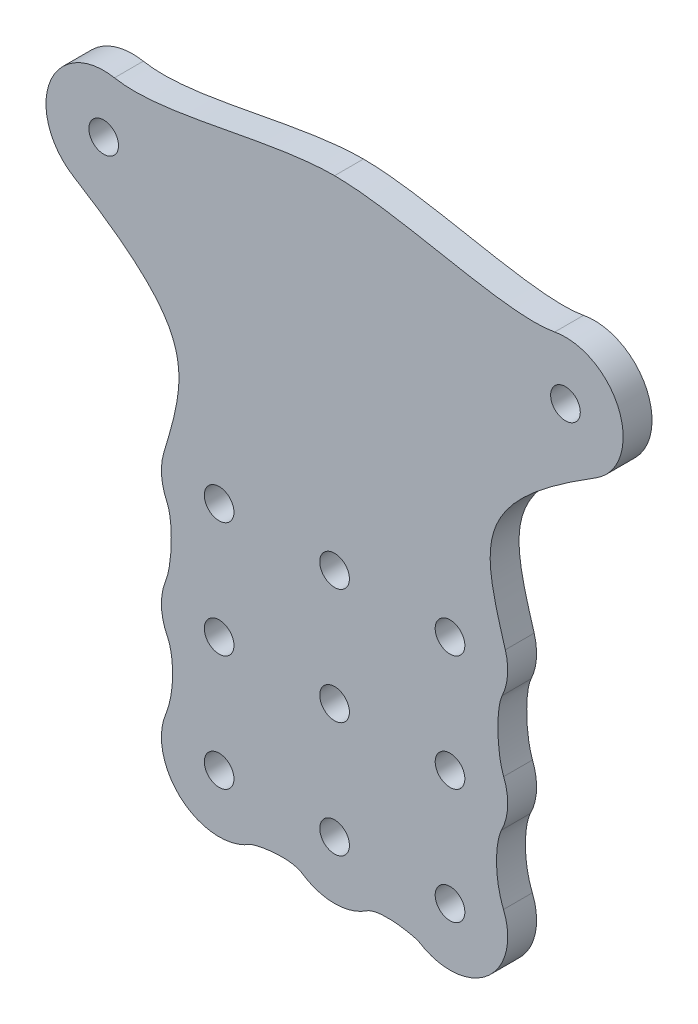
from build123d import *

# Parameters (mm, degrees)
SKETCH1_R           = 3.2639
BOSS_EXTRUDE1_DEPTH = 6.35


with BuildPart() as part:
    # Sketch1 → Boss-Extrude1 (new body)
    with BuildSketch(Plane.XY):
        with BuildLine():
            ThreePointArc((-57.473802429, -10.805108104), (-44.614019514, -11.091602473), (-38.1, 0))
            ThreePointArc((-38.1, 0), (-41.01784601, 8.099349561), (-48.430624144, 12.477021201))
            ThreePointArc((-48.430624144, 12.477021201), (-62.638344828, 4.598216146), (-57.473802429, -10.805108104))
        make_face()
        with Locations((-50.8, 0)):
            Circle(SKETCH1_R, mode=Mode.SUBTRACT)
        with BuildLine():
            ThreePointArc((-48.430624144, 12.477021201), (-41.01784601, 8.099349561), (-38.1, 0))
            ThreePointArc((-38.1, 0), (-44.614019514, -11.091602473), (-57.473802429, -10.805108104))
            add(Edge.make_bspline(
                [(-57.473802429, -10.805108104), (-30.324225084, -27.574113421), (-32.043298334, -35.040779529), (-37.567450056, -53.510884843)],
                knots=[0, 0, 0, 0, 1, 1, 1, 1], degree=3))
            ThreePointArc((-37.567450056, -53.510884843), (-23.561062225, -44.583842757), (-12.7, -57.15))
            ThreePointArc((-12.7, -57.15), (-16.419743871, -66.130256114), (-25.399999979, -69.85))
            ThreePointArc((-25.399999979, -69.85), (-16.419743871, -73.569743886), (-12.7, -82.55))
            ThreePointArc((-12.7, -82.55), (-16.419743827, -91.530256069), (-25.399999853, -95.25))
            ThreePointArc((-25.399999853, -95.25), (-16.419743827, -98.969743931), (-12.7, -107.95))
            ThreePointArc((-12.7, -107.95), (0, -95.25), (12.7, -107.95))
            ThreePointArc((12.7, -107.95), (16.419743879, -98.969743879), (25.4, -95.25))
            ThreePointArc((25.4, -95.25), (12.7, -82.55), (25.4, -69.85))
            ThreePointArc((25.4, -69.85), (15.214059629, -49.564710371), (37.567450056, -53.510884843))
            add(Edge.make_bspline(
                [(57.473802429, -10.805108104), (30.324225084, -27.574113421), (32.043298334, -35.040779529), (37.567450056, -53.510884843)],
                knots=[0, 0, 0, 0, 1, 1, 1, 1], degree=3))
            ThreePointArc((57.473802429, -10.805108104), (38.961655172, -4.598216146), (48.430624144, 12.477021201))
            add(Edge.make_bspline(
                [(48.430624144, 12.477021201), (37.357152211, 10.374178173), (14.965004226, 18.047449429), (0, 18.047449429)],
                knots=[0, 0, 0, 0, 1, 1, 1, 1], degree=3))
            add(Edge.make_bspline(
                [(-48.430624144, 12.477021201), (-37.357152211, 10.374178173), (-14.965004226, 18.047449429), (0, 18.047449429)],
                knots=[0, 0, 0, 0, 1, 1, 1, 1], degree=3))
        make_face()
        with Locations((0, -82.55)):
            Circle(SKETCH1_R, mode=Mode.SUBTRACT)
        with Locations((0, -57.15)):
            Circle(SKETCH1_R, mode=Mode.SUBTRACT)
        with BuildLine():
            ThreePointArc((-12.7, -57.15), (-23.561062225, -44.583842757), (-37.567450056, -53.510884843))
            ThreePointArc((-37.567450056, -53.510884843), (-38.064116275, -58.104022521), (-36.884933285, -62.570913894))
            ThreePointArc((-36.884933285, -62.570913894), (-32.198690804, -67.876966176), (-25.399999979, -69.85))
            ThreePointArc((-25.399999979, -69.85), (-16.419743871, -66.130256114), (-12.7, -57.15))
        make_face()
        with Locations((-25.4, -57.15)):
            Circle(SKETCH1_R, mode=Mode.SUBTRACT)
        with BuildLine():
            ThreePointArc((63.5, 0), (58.899349561, 9.78215399), (48.430624144, 12.477021201))
            ThreePointArc((48.430624144, 12.477021201), (38.961655172, -4.598216146), (57.473802429, -10.805108104))
            ThreePointArc((57.473802429, -10.805108104), (61.891602473, -6.185980486), (63.5, 0))
        make_face()
        with Locations((50.8, 0)):
            Circle(SKETCH1_R, mode=Mode.SUBTRACT)
        with BuildLine():
            ThreePointArc((-25.399999979, -69.85), (-32.198690804, -67.876966176), (-36.884933285, -62.570913894))
            add(Edge.make_bspline(
                [(-36.884933285, -62.570913894), (-35.474995699, -65.558055809), (-35.667347264, -73.999879631), (-37.201234877, -77.857361577)],
                knots=[0, 0, 0, 0, 1, 1, 1, 1], degree=3))
            ThreePointArc((-37.201234877, -77.857361577), (-32.530690422, -72.040801453), (-25.399999979, -69.85))
        make_face()
        with BuildLine():
            ThreePointArc((-12.7, -82.55), (-16.419743871, -73.569743886), (-25.399999979, -69.85))
            ThreePointArc((-25.399999979, -69.85), (-32.530690422, -72.040801453), (-37.201234877, -77.857361577))
            ThreePointArc((-37.201234877, -77.857361577), (-38.087106538, -83.122125598), (-36.730964647, -88.285785925))
            ThreePointArc((-36.730964647, -88.285785925), (-32.050019439, -93.369761617), (-25.399999853, -95.25))
            ThreePointArc((-25.399999853, -95.25), (-16.419743827, -91.530256069), (-12.7, -82.55))
        make_face()
        with Locations((-25.4, -82.55)):
            Circle(SKETCH1_R, mode=Mode.SUBTRACT)
        with BuildLine():
            ThreePointArc((38.1, -57.15), (37.966157243, -55.311062225), (37.567450056, -53.510884843))
            ThreePointArc((37.567450056, -53.510884843), (15.214059629, -49.564710371), (25.4, -69.85))
            ThreePointArc((25.4, -69.85), (32.198690813, -67.876966171), (36.884933285, -62.570913894))
            ThreePointArc((36.884933285, -62.570913894), (37.792510898, -59.927710144), (38.1, -57.15))
        make_face()
        with Locations((25.4, -57.15)):
            Circle(SKETCH1_R, mode=Mode.SUBTRACT)
        with BuildLine():
            ThreePointArc((-25.399999853, -95.25), (-32.050019439, -93.369761617), (-36.730964647, -88.285785925))
            add(Edge.make_bspline(
                [(-36.730964647, -88.285785925), (-35.529540216, -90.659183036), (-34.868854283, -97.491227569), (-37.173139537, -103.187313212)],
                knots=[0, 0, 0, 0, 1, 1, 1, 1], degree=3))
            ThreePointArc((-37.173139537, -103.187313212), (-32.499432233, -97.419659931), (-25.399999853, -95.25))
        make_face()
        with BuildLine():
            ThreePointArc((36.884933285, -62.570913894), (32.198690813, -67.876966171), (25.4, -69.85))
            ThreePointArc((25.4, -69.85), (32.53069043, -72.040801459), (37.201234877, -77.857361577))
            add(Edge.make_bspline(
                [(36.884933285, -62.570913894), (35.474995699, -65.558055809), (35.667347264, -73.999879631), (37.201234877, -77.857361577)],
                knots=[0, 0, 0, 0, 1, 1, 1, 1], degree=3))
        make_face()
        with BuildLine():
            ThreePointArc((37.201234877, -77.857361577), (32.53069043, -72.040801459), (25.4, -69.85))
            ThreePointArc((25.4, -69.85), (12.7, -82.55), (25.4, -95.25))
            ThreePointArc((25.4, -95.25), (32.050019502, -93.369761579), (36.730964647, -88.285785925))
            ThreePointArc((36.730964647, -88.285785925), (37.753000668, -85.498452898), (38.1, -82.55))
            ThreePointArc((38.1, -82.55), (37.873285111, -80.161034004), (37.201234877, -77.857361577))
        make_face()
        with Locations((25.4, -82.55)):
            Circle(SKETCH1_R, mode=Mode.SUBTRACT)
        with BuildLine():
            ThreePointArc((-12.7, -107.95), (-16.419743827, -98.969743931), (-25.399999853, -95.25))
            ThreePointArc((-25.399999853, -95.25), (-32.499432233, -97.419659931), (-37.173139537, -103.187313212))
            ThreePointArc((-37.173139537, -103.187313212), (-33.490567042, -117.73941903), (-18.505322211, -118.615524749))
            ThreePointArc((-18.505322211, -118.615524749), (-14.245350567, -114.021556311), (-12.7, -107.95))
        make_face()
        with Locations((-25.4, -107.95)):
            Circle(SKETCH1_R, mode=Mode.SUBTRACT)
        with BuildLine():
            ThreePointArc((36.730964647, -88.285785925), (32.050019502, -93.369761579), (25.4, -95.25))
            ThreePointArc((25.4, -95.25), (32.499432294, -97.419659972), (37.173139537, -103.187313212))
            add(Edge.make_bspline(
                [(36.730964647, -88.285785925), (35.529540216, -90.659183036), (34.868854283, -97.491227569), (37.173139537, -103.187313212)],
                knots=[0, 0, 0, 0, 1, 1, 1, 1], degree=3))
        make_face()
        with BuildLine():
            ThreePointArc((37.173139537, -103.187313212), (32.499432294, -97.419659972), (25.4, -95.25))
            ThreePointArc((25.4, -95.25), (16.419743879, -98.969743879), (12.7, -107.95))
            ThreePointArc((12.7, -107.95), (14.245350567, -114.021556311), (18.505322211, -118.615524749))
            ThreePointArc((18.505322211, -118.615524749), (31.471556311, -119.104649433), (38.1, -107.95))
            ThreePointArc((38.1, -107.95), (37.86613156, -105.523981876), (37.173139537, -103.187313212))
        make_face()
        with Locations((25.4, -107.95)):
            Circle(SKETCH1_R, mode=Mode.SUBTRACT)
        with BuildLine():
            ThreePointArc((12.7, -107.95), (0, -95.25), (-12.7, -107.95))
            ThreePointArc((-12.7, -107.95), (-11.196292989, -113.94441601), (-7.041256172, -118.519328811))
            ThreePointArc((-7.041256172, -118.519328811), (0, -120.65), (7.041256172, -118.519328811))
            ThreePointArc((7.041256172, -118.519328811), (11.196292989, -113.94441601), (12.7, -107.95))
        make_face()
        with Locations((0, -107.95)):
            Circle(SKETCH1_R, mode=Mode.SUBTRACT)
        with BuildLine():
            ThreePointArc((-7.041256172, -118.519328811), (-11.196292989, -113.94441601), (-12.7, -107.95))
            ThreePointArc((-12.7, -107.95), (-14.245350567, -114.021556311), (-18.505322211, -118.615524749))
            add(Edge.make_bspline(
                [(-18.505322211, -118.615524749), (-17.94171439, -118.251183152), (-10.184581564, -116.42525456), (-7.041256172, -118.519328811)],
                knots=[0, 0, 0, 0, 1, 1, 1, 1], degree=3))
        make_face()
        with BuildLine():
            ThreePointArc((18.505322211, -118.615524749), (14.245350567, -114.021556311), (12.7, -107.95))
            ThreePointArc((12.7, -107.95), (11.196292989, -113.94441601), (7.041256172, -118.519328811))
            add(Edge.make_bspline(
                [(18.505322211, -118.615524749), (17.94171439, -118.251183152), (10.184581564, -116.42525456), (7.041256172, -118.519328811)],
                knots=[0, 0, 0, 0, 1, 1, 1, 1], degree=3))
        make_face()
    extrude(amount=BOSS_EXTRUDE1_DEPTH)


solid = part.part
